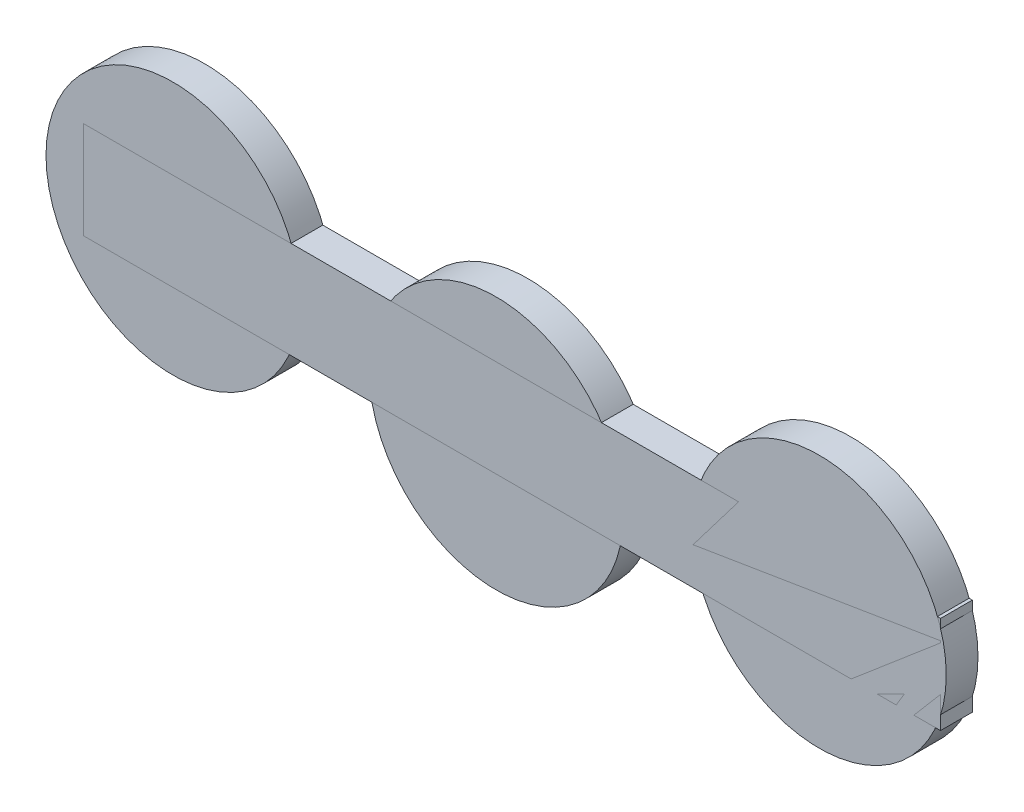
from build123d import *

# Parameters (mm, degrees)
SKETCH4_R             = 101.6
BOSS_EXTRUDE1_DEPTH   = 25.4
BOSS_EXTRUDE1_2_DEPTH = 25.4
BOSS_EXTRUDE1_3_DEPTH = 25.4
SKETCH5_W             = 685.8
SKETCH5_H             = 77.724
BOSS_EXTRUDE2_DEPTH   = 25.4


with BuildPart() as part:
    # Sketch4 → Boss-Extrude1 (new body)
    with BuildSketch(Plane.XY):
        with Locations((-97.791162832, -40.386)):
            Circle(SKETCH4_R)
    extrude(amount=BOSS_EXTRUDE1_DEPTH)


with BuildPart() as body_2:
    # Sketch4 → Boss-Extrude1 2 (new body)
    with BuildSketch(Plane.XY):
        with Locations((-356.362, -59.944)):
            Circle(SKETCH4_R)
    extrude(amount=BOSS_EXTRUDE1_2_DEPTH)


with BuildPart() as body_3:
    # Sketch4 → Boss-Extrude1 3 (new body)
    with BuildSketch(Plane.XY):
        with Locations((-614.932837168, -40.386)):
            Circle(SKETCH4_R)
    extrude(amount=BOSS_EXTRUDE1_3_DEPTH)


with BuildPart() as body_4:
    # Sketch5 → Boss-Extrude2 (new body)
    with BuildSketch(Plane.XY):
        with Locations((-343.662, -42.291)):
            Rectangle(SKETCH5_W, SKETCH5_H)
    extrude(amount=BOSS_EXTRUDE2_DEPTH)


solid = Compound([part.part, body_2.part, body_3.part, body_4.part])
